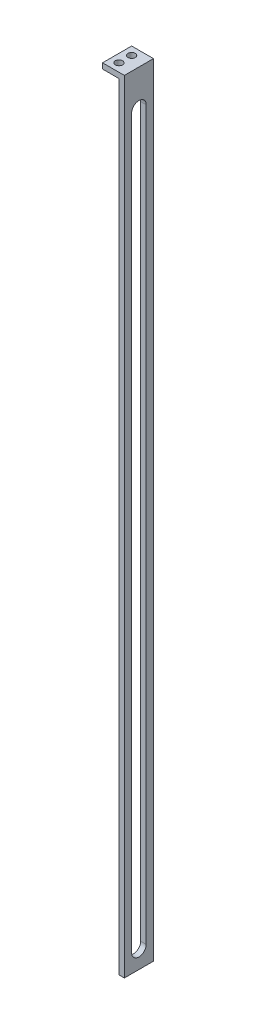
from build123d import *

# Parameters (mm, degrees)
BOSS_EXTRUDE1_DEPTH     = 16
SKETCH2_R               = 2
CUT_EXTRUDE1_DEPTH      = 110.166666667
CUT_EXTRUDE1_DEPTH_BACK = 321.833333333
CUT_EXTRUDE2_DEPTH      = 97.666666667


with BuildPart() as part:
    # Sketch1 → Boss-Extrude1 (new body)
    with BuildSketch(Plane.XY):
        Polygon((-96.666666667, 109.166666667), (-84.666666667, 109.166666667), (-84.666666667, -320.833333333), (-87.666666667, -320.833333333), (-87.666666667, 106.166666667), (-96.666666667, 106.166666667), align=None)
    extrude(amount=BOSS_EXTRUDE1_DEPTH)

    # Sketch2 → Cut-Extrude1 (cut, two sides)
    with BuildSketch(Plane(origin=(0, 0, 0), x_dir=(1, 0, 0), z_dir=(0, 1, 0))) as cut_extrude1_sk:
        with Locations((-92.166666667, -11.5)):
            Circle(SKETCH2_R)
        with Locations((-92.166666667, -4.5)):
            Circle(SKETCH2_R)
    extrude(amount=CUT_EXTRUDE1_DEPTH, mode=Mode.SUBTRACT)
    extrude(cut_extrude1_sk.sketch, amount=-CUT_EXTRUDE1_DEPTH_BACK, mode=Mode.SUBTRACT)

    # Sketch3 → Cut-Extrude2 (cut, through all)
    with BuildSketch(Plane(origin=(0, 0, 0), x_dir=(0, 0, -1), z_dir=(1, 0, 0))):
        with BuildLine():
            Line((-4, 89.166666667), (-4, -310.833333333))
            ThreePointArc((-4, -310.833333333), (-8, -314.833333333), (-12, -310.833333333))
            Line((-12, -310.833333333), (-12, 89.166666667))
            ThreePointArc((-12, 89.166666667), (-8, 93.166666667), (-4, 89.166666667))
        make_face()
    extrude(amount=-CUT_EXTRUDE2_DEPTH, mode=Mode.SUBTRACT)


solid = part.part
